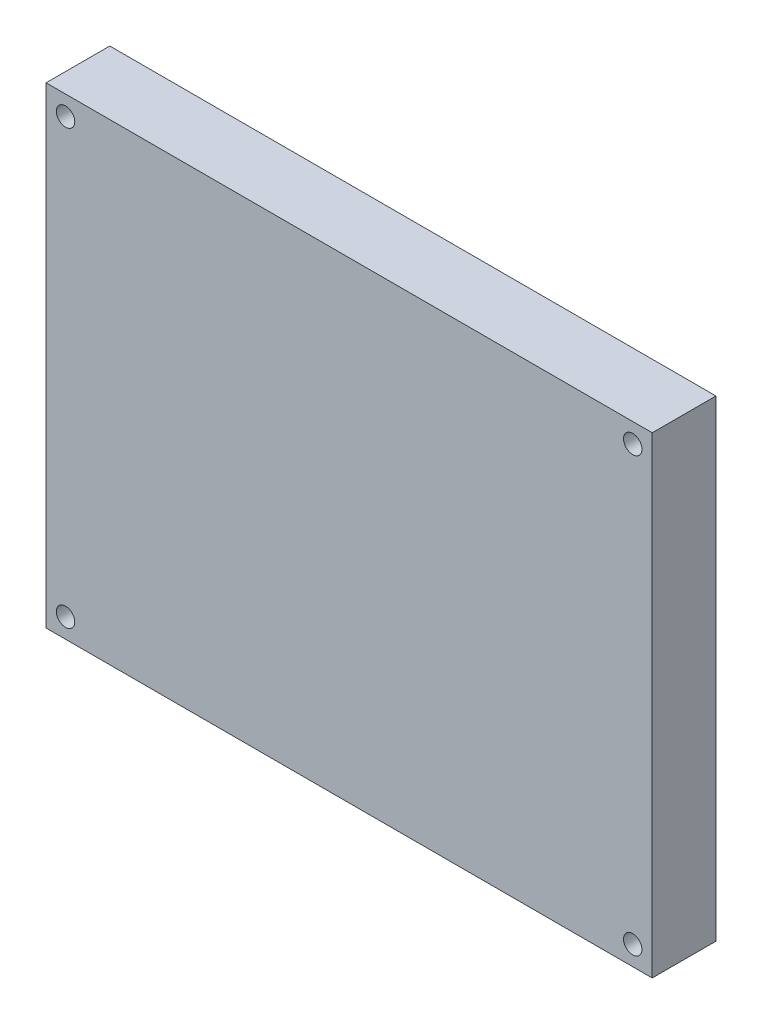
from build123d import *

# Parameters (mm, degrees)
SKETCH_1_W      = 95.15
SKETCH_1_H      = 74.12
SKETCH_1_R      = 1.445
EXTRUDE_1_DEPTH = 10


with BuildPart() as part:
    # Эскиз1 → Бобышка-Вытянуть1 (new body)
    with BuildSketch(Plane.XY):
        with Locations((-44.970501877, 24.396724937)):
            Rectangle(SKETCH_1_W, SKETCH_1_H)
        with Locations((-0.455501877, 58.396724937)):
            Circle(SKETCH_1_R, mode=Mode.SUBTRACT)
        with Locations((-89.485501877, 58.396724937)):
            Circle(SKETCH_1_R, mode=Mode.SUBTRACT)
        with Locations((-89.485501877, -9.603275063)):
            Circle(SKETCH_1_R, mode=Mode.SUBTRACT)
        with Locations((-0.455501877, -9.603275063)):
            Circle(SKETCH_1_R, mode=Mode.SUBTRACT)
    extrude(amount=EXTRUDE_1_DEPTH)


solid = part.part
